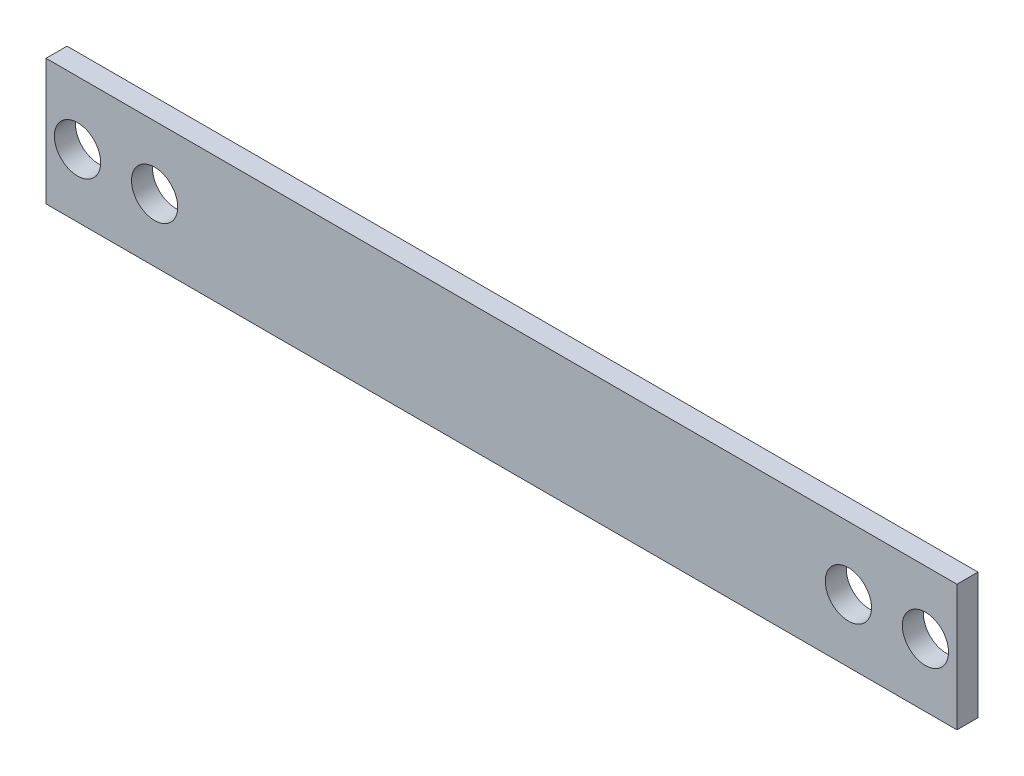
from build123d import *

# Parameters (mm, degrees)
SKETCH1_W           = 65
SKETCH1_H           = 9
SKETCH1_R           = 1.65
BOSS_EXTRUDE1_DEPTH = 1.5


with BuildPart() as part:
    # Sketch1 → Boss-Extrude1 (new body)
    with BuildSketch(Plane.XY):
        Rectangle(SKETCH1_W, SKETCH1_H)
        with Locations((-30.25, 0)):
            Circle(SKETCH1_R, mode=Mode.SUBTRACT)
        with Locations((24.75, 0)):
            Circle(SKETCH1_R, mode=Mode.SUBTRACT)
        with Locations((30.25, 0)):
            Circle(SKETCH1_R, mode=Mode.SUBTRACT)
        with Locations((-24.75, 0)):
            Circle(SKETCH1_R, mode=Mode.SUBTRACT)
    extrude(amount=BOSS_EXTRUDE1_DEPTH)


solid = part.part
